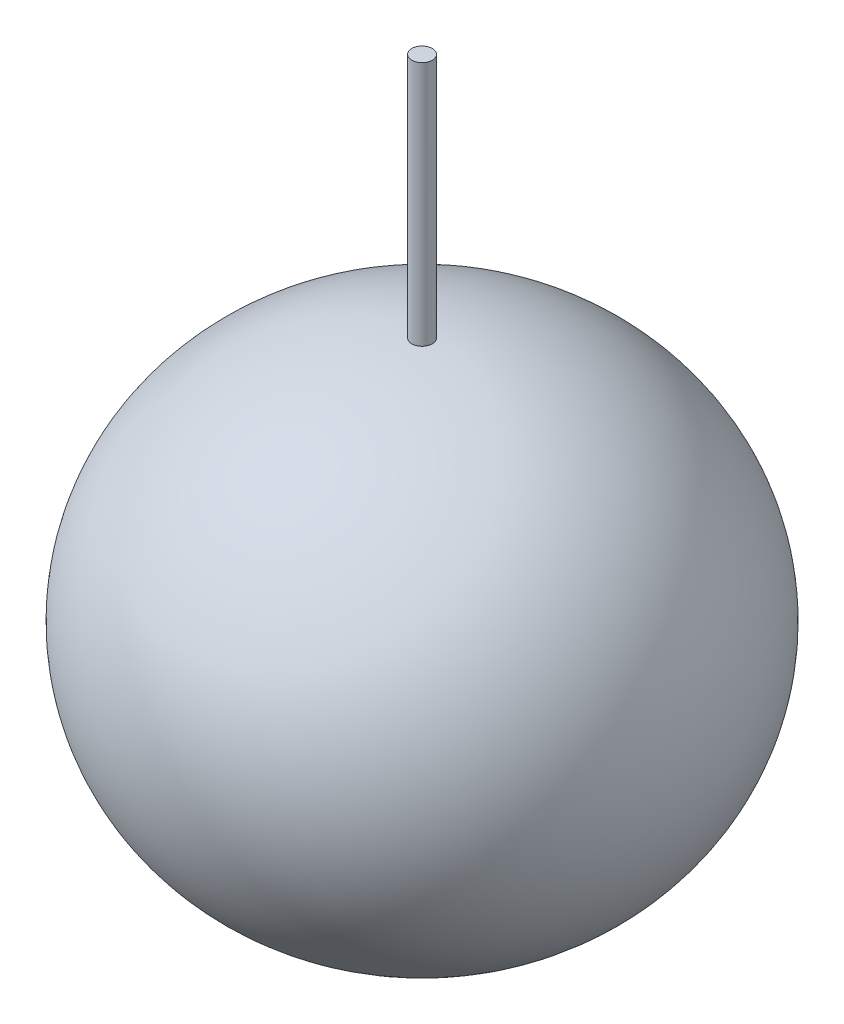
from build123d import *

# Parameters (mm, degrees)
SKETCH_2_R = 1.25


with BuildPart() as part:
    # 草图1 → 旋转4 (revolve)
    with BuildSketch(Plane.XY):
        with BuildLine():
            Line((0, 30), (0, -30))
            add(Edge.make_bspline(
                [(0, -30), (32.5, -30), (32.5, 0), (32.5, 30), (0, 30)],
                knots=[1.570796327, 1.570796327, 1.570796327, 3.141592654, 3.141592654, 4.71238898, 4.71238898, 4.71238898], degree=2, weights=[1, 0.707106781, 1, 0.707106781, 1]))
        make_face()
    revolve(axis=Axis((0, 30, 0), (0, -1, 0)))

    # 扫描1: sweep along a path in 草图3
    with BuildLine(Plane.XY) as sweep_1_path:
        Line((0, 0), (0, 60))
    # 草图2 → 扫描1 (sweep)
    with BuildSketch(Plane(origin=(0, 0, 0), x_dir=(1, 0, 0), z_dir=(0, 1, 0))):
        Circle(SKETCH_2_R)
    sweep(path=sweep_1_path.line)


solid = part.part
